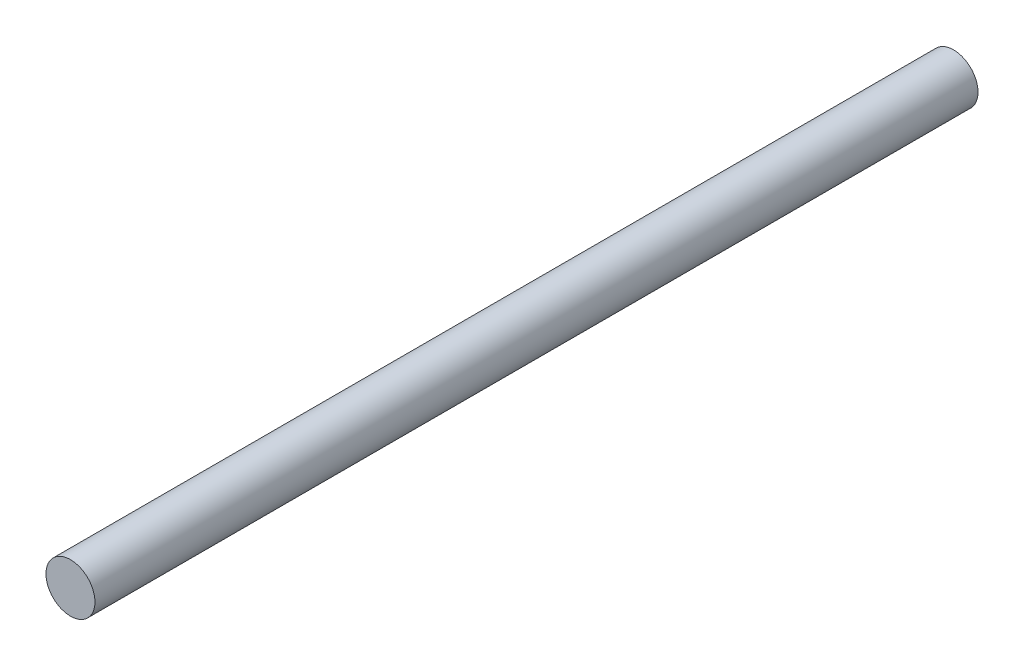
from build123d import *

# Parameters (mm, degrees)
SKETCH1_R           = 2.080050088
BOSS_EXTRUDE1_DEPTH = 75


with BuildPart() as part:
    # Sketch1 → Boss-Extrude1 (new body)
    with BuildSketch(Plane.XY):
        with Locations((11.574002988, 0.208079197)):
            Circle(SKETCH1_R)
    extrude(amount=-BOSS_EXTRUDE1_DEPTH)


solid = part.part
